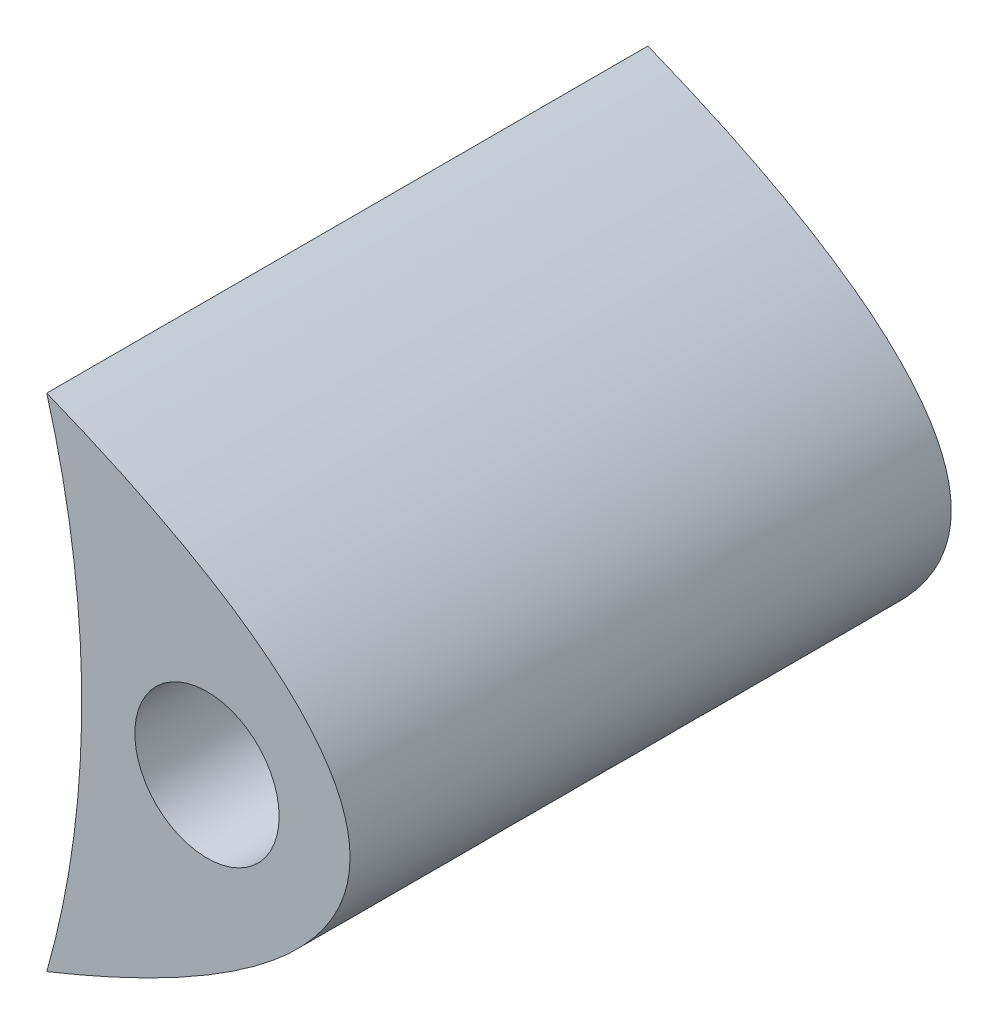
from build123d import *

# Parameters (mm, degrees)
BOSS_EXTRUDE1_DEPTH       = 15.24
F_6_CLEARANCE_HOLE2_D     = 3.6576
F_6_CLEARANCE_HOLE2_DEPTH = 15.241


with BuildPart() as part:
    # Sketch1 → Boss-Extrude1 (new body)
    with BuildSketch(Plane.XY):
        with BuildLine():
            ThreePointArc((-4.061784119, 6.35), (-3.175, 0), (-4.061784119, -6.35))
            add(Edge.make_bspline(
                [(-4.061784119, -6.35), (11.775385187, 0), (-4.061784119, 6.35)],
                knots=[5.945724399, 5.945724399, 5.945724399, 6.620646215, 6.620646215, 6.620646215], degree=2, weights=[1, 0.94359838, 1]))
        make_face()
    extrude(amount=-BOSS_EXTRUDE1_DEPTH)

    # #6 Clearance Hole2
    with Locations(Plane.XY):
        with Locations((0, 0)):
            Hole(F_6_CLEARANCE_HOLE2_D / 2, depth=F_6_CLEARANCE_HOLE2_DEPTH)


solid = part.part
